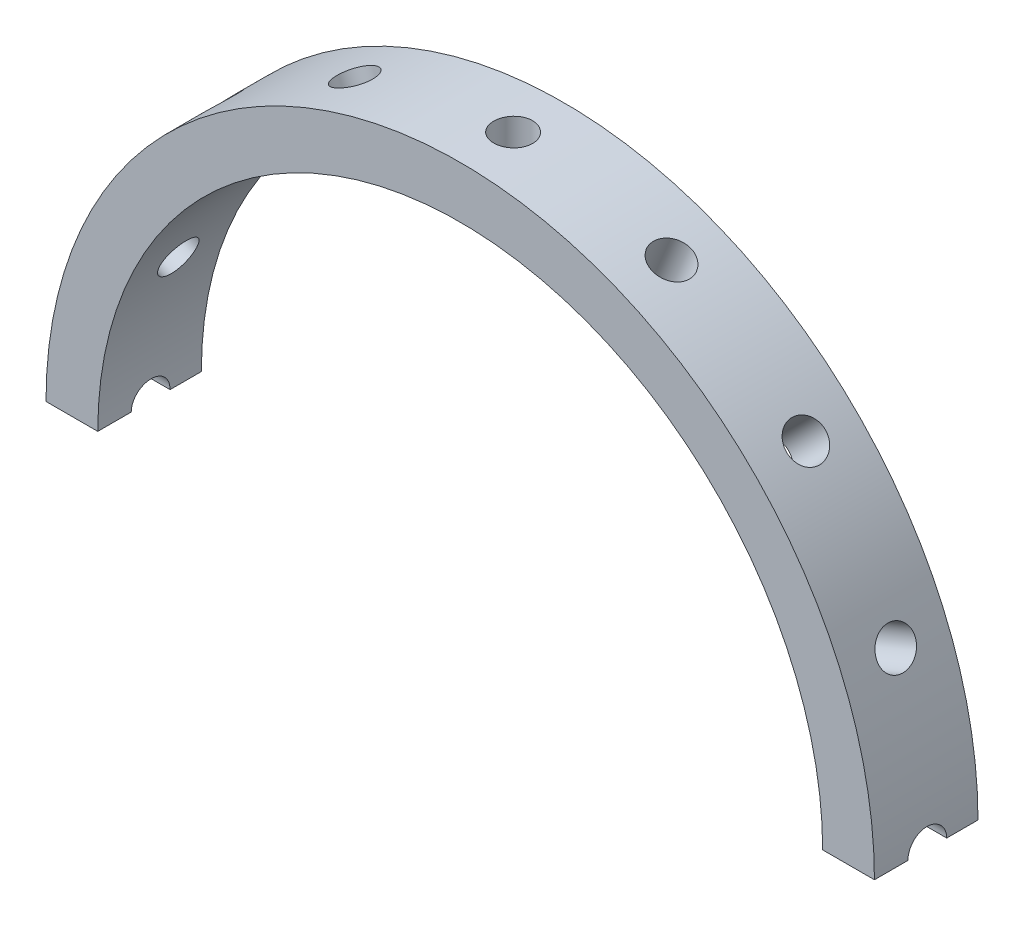
from build123d import *

# Parameters (mm, degrees)
SKETCH_1_R               = 16
SKETCH_1_R_2             = 14
EXTRUDE_1_DEPTH          = 4
SKETCH_2_R               = 0.75
CUT_EXTRUDE_1_DEPTH      = 17
PATTERN_CIRCULAR_1_COUNT = 16
SKETCH_3_W               = 36.79853237
SKETCH_3_H               = 11.94610836
CUT_EXTRUDE_2_DEPTH      = 17.0000001


with BuildPart() as part:
    # ｽｹｯﾁ1 → ﾎﾞｽ - 押し出し1 (new body)
    with BuildSketch(Plane.XY):
        Circle(SKETCH_1_R)
        Circle(SKETCH_1_R_2, mode=Mode.SUBTRACT)
    extrude(amount=EXTRUDE_1_DEPTH)

    # ｽｹｯﾁ2 → ｶｯﾄ - 押し出し1 (cut, through all)
    with BuildSketch(Plane(origin=(0, 0, 0), x_dir=(1, 0, 0), z_dir=(0, 1, 0))):
        with Locations((0, -1.957637914)):
            Circle(SKETCH_2_R)
    cut_extrude_1 = extrude(amount=-CUT_EXTRUDE_1_DEPTH, mode=Mode.SUBTRACT)

    # 円形ﾊﾟﾀｰﾝ1: ｶｯﾄ - 押し出し1 ×16 about axis
    pattern_circular_1_axis = Axis((0, 0, 0), (0, 0, 1))
    for i in range(1, PATTERN_CIRCULAR_1_COUNT):
        add(cut_extrude_1.rotate(pattern_circular_1_axis, i * 360 / PATTERN_CIRCULAR_1_COUNT), mode=Mode.SUBTRACT)

    # ｽｹｯﾁ3 → ｶｯﾄ - 押し出し2 (cut, through all)
    with BuildSketch(Plane(origin=(0, 0, 0), x_dir=(1, 0, 0), z_dir=(0, 1, 0))):
        with Locations((0, -2.028241391)):
            Rectangle(SKETCH_3_W, SKETCH_3_H)
    extrude(amount=-CUT_EXTRUDE_2_DEPTH, mode=Mode.SUBTRACT)


solid = part.part
